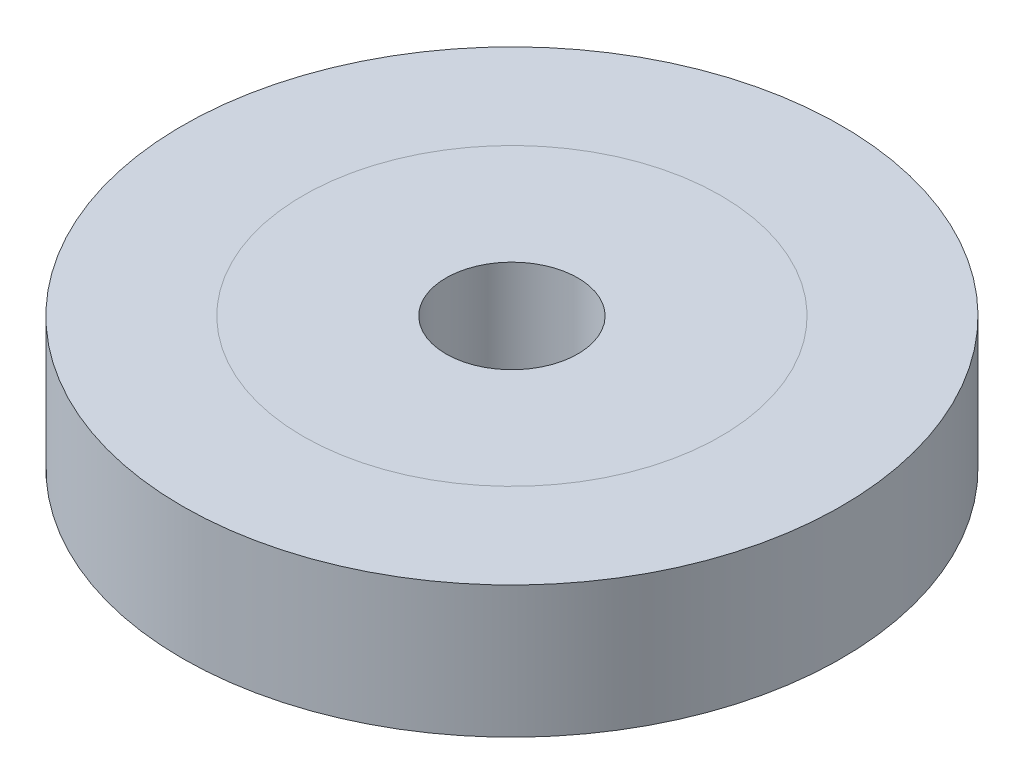
from build123d import *

# Parameters (mm, degrees)
SKETCH_1_R      = 9.5
SKETCH_1_R_2    = 3
EXTRUDE_1_DEPTH = 3
SKETCH_2_R      = 15
SKETCH_2_R_2    = 9.5
EXTRUDE_2_DEPTH = 3


with BuildPart() as part:
    # 草图1 → 凸台-拉伸1 (new body, symmetric)
    with BuildSketch(Plane(origin=(0, 0, 0), x_dir=(1, 0, 0), z_dir=(0, 1, 0))):
        Circle(SKETCH_1_R)
        Circle(SKETCH_1_R_2, mode=Mode.SUBTRACT)
    extrude(amount=EXTRUDE_1_DEPTH, both=True)


with BuildPart() as body_2:
    # 草图2 → 凸台-拉伸2 (new body, symmetric)
    with BuildSketch(Plane(origin=(0, 0, 0), x_dir=(1, 0, 0), z_dir=(0, 1, 0))):
        Circle(SKETCH_2_R)
        Circle(SKETCH_2_R_2, mode=Mode.SUBTRACT)
    extrude(amount=EXTRUDE_2_DEPTH, both=True)


solid = Compound([part.part, body_2.part])
